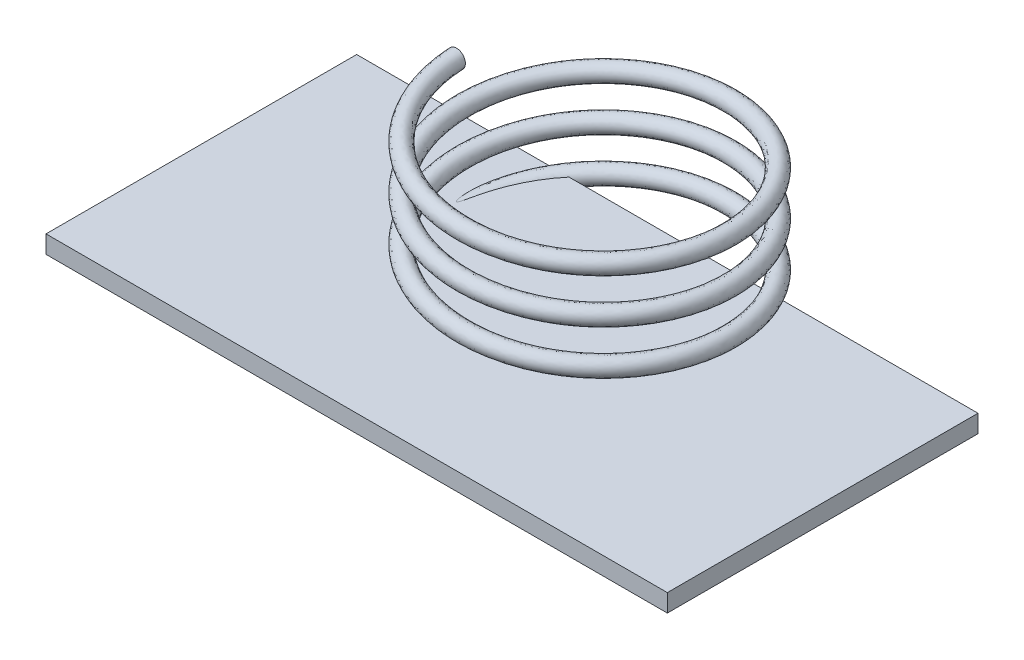
from build123d import *

# Parameters (mm, degrees)
SWEEP1_PITCH             = 1
SWEEP1_HEIGHT            = 3
SWEEP1_RADIUS            = 3
SWEEP1_START_ANGLE       = -90
SKETCH7_R                = 0.2
SKETCH8_W                = 14
SKETCH8_H                = 7
BOSS_EXTRUDE2_DEPTH      = 0.2
BOSS_EXTRUDE2_DEPTH_BACK = 0.2


with BuildPart() as part:
    # Sweep1: sweep along a helix
    with BuildLine() as sweep1_path:
        add(Helix(SWEEP1_PITCH, SWEEP1_HEIGHT, SWEEP1_RADIUS, center=(0, 0, 0), direction=(0, 1, 0), lefthand=True, mode=Mode.PRIVATE).rotate(Axis((0, 0, 0), (0, 1, 0)), SWEEP1_START_ANGLE))
    # Sketch7 → Sweep1 (sweep)
    with BuildSketch(Plane.XY):
        with Locations((-3, 0)):
            Circle(SKETCH7_R)
    sweep(path=sweep1_path.line, is_frenet=True)

    # Sketch8 → Boss-Extrude2 (add, two sides)
    with BuildSketch(Plane(origin=(0, 0, 0), x_dir=(1, 0, 0), z_dir=(0, 1, 0))) as boss_extrude2_sk:
        with Locations((0, -1.75)):
            Rectangle(SKETCH8_W, SKETCH8_H)
    extrude(amount=BOSS_EXTRUDE2_DEPTH)
    extrude(boss_extrude2_sk.sketch, amount=-BOSS_EXTRUDE2_DEPTH_BACK)


solid = part.part
